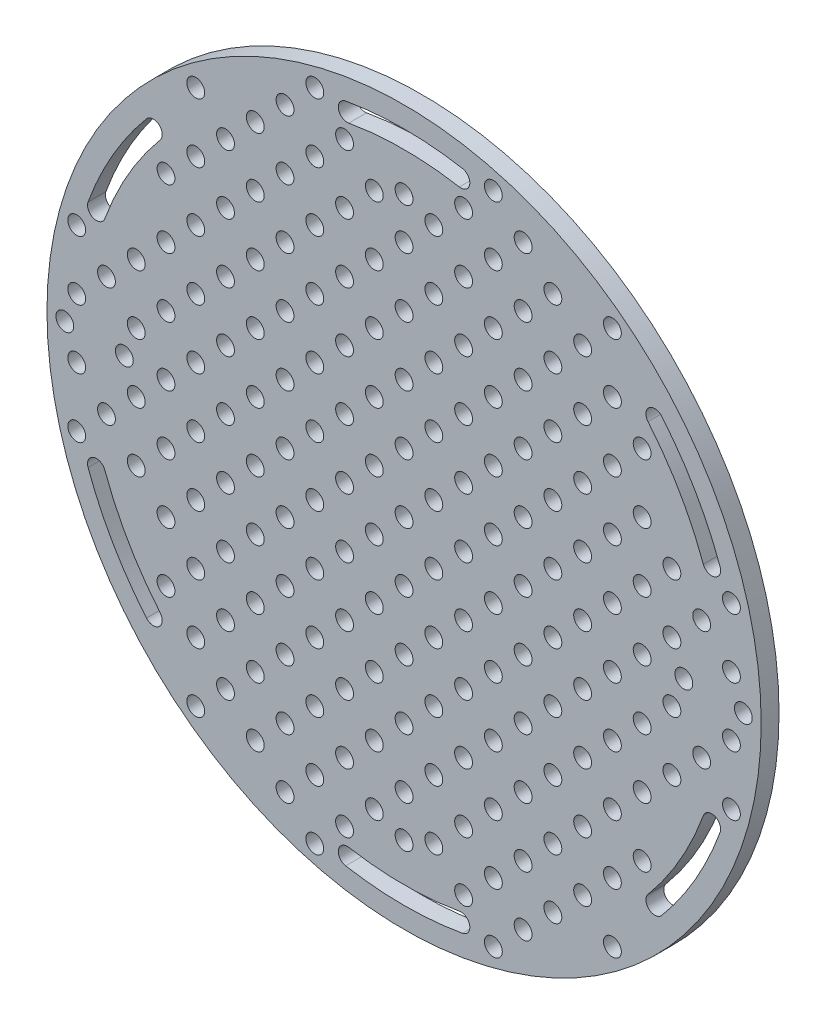
from build123d import *

# Parameters (mm, degrees)
ESQUISSE1_R             = 50
ESQUISSE1_R_2           = 1.5
BOSS_EXTRU_1_DEPTH      = 3
ESQUISSE2_R             = 60
ESQUISSE2_R_2           = 50
BOSS_EXTRU_2_DEPTH      = 3
ESQUISSE3_R             = 1.5
ENL_V_MAT_EXTRU_1_DEPTH = 3
ENL_V_MAT_EXTRU_3_DEPTH = 3
ESQUISSE10_R            = 1.5
ENL_V_MAT_EXTRU_7_DEPTH = 3
ESQUISSE11_R            = 1.5
ENL_V_MAT_EXTRU_8_DEPTH = 3


with BuildPart() as part:
    # Esquisse1 → Boss.-Extru.1 (new body)
    with BuildSketch(Plane.XY):
        Circle(ESQUISSE1_R)
        with Locations((0, 47)):
            Circle(ESQUISSE1_R_2, mode=Mode.SUBTRACT)
        with Locations((47, 0)):
            Circle(ESQUISSE1_R_2, mode=Mode.SUBTRACT)
        with Locations((0, -47)):
            Circle(ESQUISSE1_R_2, mode=Mode.SUBTRACT)
        with Locations((-47, 0)):
            Circle(ESQUISSE1_R_2, mode=Mode.SUBTRACT)
    extrude(amount=BOSS_EXTRU_1_DEPTH)

    # Esquisse2 → Boss.-Extru.2 (add)
    with BuildSketch(Plane.XY.offset(3)):
        Circle(ESQUISSE2_R)
        Circle(ESQUISSE2_R_2, mode=Mode.SUBTRACT)
    extrude(amount=-BOSS_EXTRU_2_DEPTH)

    # Esquisse3 → Enlèv. mat.-Extru.1 (cut)
    with BuildSketch(Plane.XY.offset(3)):
        Circle(ESQUISSE3_R)
        with Locations((10, 0)):
            Circle(ESQUISSE3_R)
        with Locations((20, 0)):
            Circle(ESQUISSE3_R)
        with Locations((30, 0)):
            Circle(ESQUISSE3_R)
        with Locations((40, 0)):
            Circle(ESQUISSE3_R)
        with Locations((10, 10)):
            Circle(ESQUISSE3_R)
        with Locations((20, 10)):
            Circle(ESQUISSE3_R)
        with Locations((30, 10)):
            Circle(ESQUISSE3_R)
        with Locations((40, 10)):
            Circle(ESQUISSE3_R)
        with Locations((10, 20)):
            Circle(ESQUISSE3_R)
        with Locations((20, 20)):
            Circle(ESQUISSE3_R)
        with Locations((30, 20)):
            Circle(ESQUISSE3_R)
        with Locations((40, 20)):
            Circle(ESQUISSE3_R)
        with Locations((10, 30)):
            Circle(ESQUISSE3_R)
        with Locations((20, 30)):
            Circle(ESQUISSE3_R)
        with Locations((30, 30)):
            Circle(ESQUISSE3_R)
        with Locations((10, 40)):
            Circle(ESQUISSE3_R)
        with Locations((20, 40)):
            Circle(ESQUISSE3_R)
        with Locations((0, 10)):
            Circle(ESQUISSE3_R)
        with Locations((0, 20)):
            Circle(ESQUISSE3_R)
        with Locations((0, 30)):
            Circle(ESQUISSE3_R)
        with Locations((0, 40)):
            Circle(ESQUISSE3_R)
        with Locations((-20, 40)):
            Circle(ESQUISSE3_R)
        with Locations((-10, 40)):
            Circle(ESQUISSE3_R)
        with Locations((-30, 30)):
            Circle(ESQUISSE3_R)
        with Locations((-20, 30)):
            Circle(ESQUISSE3_R)
        with Locations((-10, 30)):
            Circle(ESQUISSE3_R)
        with Locations((-40, 20)):
            Circle(ESQUISSE3_R)
        with Locations((-30, 20)):
            Circle(ESQUISSE3_R)
        with Locations((-20, 20)):
            Circle(ESQUISSE3_R)
        with Locations((-10, 20)):
            Circle(ESQUISSE3_R)
        with Locations((-40, 10)):
            Circle(ESQUISSE3_R)
        with Locations((-30, 10)):
            Circle(ESQUISSE3_R)
        with Locations((-20, 10)):
            Circle(ESQUISSE3_R)
        with Locations((-10, 10)):
            Circle(ESQUISSE3_R)
        with Locations((-40, 0)):
            Circle(ESQUISSE3_R)
        with Locations((-30, 0)):
            Circle(ESQUISSE3_R)
        with Locations((-20, 0)):
            Circle(ESQUISSE3_R)
        with Locations((-10, 0)):
            Circle(ESQUISSE3_R)
        with Locations((-10, -10)):
            Circle(ESQUISSE3_R)
        with Locations((-20, -10)):
            Circle(ESQUISSE3_R)
        with Locations((-30, -10)):
            Circle(ESQUISSE3_R)
        with Locations((-40, -10)):
            Circle(ESQUISSE3_R)
        with Locations((-10, -20)):
            Circle(ESQUISSE3_R)
        with Locations((-20, -20)):
            Circle(ESQUISSE3_R)
        with Locations((-30, -20)):
            Circle(ESQUISSE3_R)
        with Locations((-40, -20)):
            Circle(ESQUISSE3_R)
        with Locations((-10, -30)):
            Circle(ESQUISSE3_R)
        with Locations((-20, -30)):
            Circle(ESQUISSE3_R)
        with Locations((-30, -30)):
            Circle(ESQUISSE3_R)
        with Locations((-10, -40)):
            Circle(ESQUISSE3_R)
        with Locations((-20, -40)):
            Circle(ESQUISSE3_R)
        with Locations((0, -40)):
            Circle(ESQUISSE3_R)
        with Locations((0, -30)):
            Circle(ESQUISSE3_R)
        with Locations((0, -20)):
            Circle(ESQUISSE3_R)
        with Locations((0, -10)):
            Circle(ESQUISSE3_R)
        with Locations((20, -40)):
            Circle(ESQUISSE3_R)
        with Locations((10, -40)):
            Circle(ESQUISSE3_R)
        with Locations((30, -30)):
            Circle(ESQUISSE3_R)
        with Locations((20, -30)):
            Circle(ESQUISSE3_R)
        with Locations((10, -30)):
            Circle(ESQUISSE3_R)
        with Locations((40, -20)):
            Circle(ESQUISSE3_R)
        with Locations((30, -20)):
            Circle(ESQUISSE3_R)
        with Locations((20, -20)):
            Circle(ESQUISSE3_R)
        with Locations((10, -20)):
            Circle(ESQUISSE3_R)
        with Locations((40, -10)):
            Circle(ESQUISSE3_R)
        with Locations((30, -10)):
            Circle(ESQUISSE3_R)
        with Locations((20, -10)):
            Circle(ESQUISSE3_R)
        with Locations((10, -10)):
            Circle(ESQUISSE3_R)
    extrude(amount=-ENL_V_MAT_EXTRU_1_DEPTH, mode=Mode.SUBTRACT)

    # Esquisse4 → Enlèv. mat.-Extru.3 (cut)
    with BuildSketch(Plane.XY.offset(3)):
        with BuildLine():
            ThreePointArc((9.811122038, 55.641638045), (0, 56.5), (-9.811122038, 55.641638045))
            ThreePointArc((-9.811122038, 55.641638045), (-11.027861401, 53.903954149), (-9.290177505, 52.687214786))
            ThreePointArc((-9.290177505, 52.687214786), (0, 53.5), (9.290177505, 52.687214786))
            ThreePointArc((9.290177505, 52.687214786), (11.027861401, 53.903954149), (9.811122038, 55.641638045))
        make_face()
        with BuildLine():
            ThreePointArc((53.092633074, 19.324138098), (48.930435314, 28.25), (43.281511036, 36.317499947))
            ThreePointArc((43.281511036, 36.317499947), (41.168262957, 36.502385197), (40.983377707, 34.389137118))
            ThreePointArc((40.983377707, 34.389137118), (46.332359102, 26.75), (50.273555212, 18.298077668))
            ThreePointArc((50.273555212, 18.298077668), (52.196124358, 17.401568952), (53.092633074, 19.324138098))
        make_face()
        with BuildLine():
            ThreePointArc((43.281511036, -36.317499947), (48.930435314, -28.25), (53.092633074, -19.324138098))
            ThreePointArc((53.092633074, -19.324138098), (52.196124358, -17.401568952), (50.273555212, -18.298077668))
            ThreePointArc((50.273555212, -18.298077668), (46.332359102, -26.75), (40.983377707, -34.389137118))
            ThreePointArc((40.983377707, -34.389137118), (41.168262957, -36.502385197), (43.281511036, -36.317499947))
        make_face()
        with BuildLine():
            ThreePointArc((-9.811122038, -55.641638045), (0, -56.5), (9.811122038, -55.641638045))
            ThreePointArc((9.811122038, -55.641638045), (11.027861401, -53.903954149), (9.290177505, -52.687214786))
            ThreePointArc((9.290177505, -52.687214786), (0, -53.5), (-9.290177505, -52.687214786))
            ThreePointArc((-9.290177505, -52.687214786), (-11.027861401, -53.903954149), (-9.811122038, -55.641638045))
        make_face()
        with BuildLine():
            ThreePointArc((-53.092633074, -19.324138098), (-48.930435314, -28.25), (-43.281511036, -36.317499947))
            ThreePointArc((-43.281511036, -36.317499947), (-41.168262957, -36.502385197), (-40.983377707, -34.389137118))
            ThreePointArc((-40.983377707, -34.389137118), (-46.332359102, -26.75), (-50.273555212, -18.298077668))
            ThreePointArc((-50.273555212, -18.298077668), (-52.196124358, -17.401568952), (-53.092633074, -19.324138098))
        make_face()
        with BuildLine():
            ThreePointArc((-43.281511036, 36.317499947), (-48.930435314, 28.25), (-53.092633074, 19.324138098))
            ThreePointArc((-53.092633074, 19.324138098), (-52.196124358, 17.401568952), (-50.273555212, 18.298077668))
            ThreePointArc((-50.273555212, 18.298077668), (-46.332359102, 26.75), (-40.983377707, 34.389137118))
            ThreePointArc((-40.983377707, 34.389137118), (-41.168262957, 36.502385197), (-43.281511036, 36.317499947))
        make_face()
    extrude(amount=-ENL_V_MAT_EXTRU_3_DEPTH, mode=Mode.SUBTRACT)

    # Esquisse10 → Enlèv. mat.-Extru.7 (cut)
    with BuildSketch(Plane(origin=(0, 0, 0), x_dir=(-1, 0, 0), z_dir=(0, 0, -1))):
        with Locations((-10, 50)):
            Circle(ESQUISSE10_R)
        with Locations((-20, 50)):
            Circle(ESQUISSE10_R)
        with Locations((-30, 40)):
            Circle(ESQUISSE10_R)
        with Locations((-40, 30)):
            Circle(ESQUISSE10_R)
        with Locations((-50, 10)):
            Circle(ESQUISSE10_R)
        with Locations((-57, 0)):
            Circle(ESQUISSE10_R)
        with Locations((-50, -10)):
            Circle(ESQUISSE10_R)
        with Locations((-40, -30)):
            Circle(ESQUISSE10_R)
        with Locations((-30, -40)):
            Circle(ESQUISSE10_R)
        with Locations((-20, -50)):
            Circle(ESQUISSE10_R)
        with Locations((-10, -50)):
            Circle(ESQUISSE10_R)
        with Locations((10, -50)):
            Circle(ESQUISSE10_R)
        with Locations((20, -50)):
            Circle(ESQUISSE10_R)
        with Locations((30, -40)):
            Circle(ESQUISSE10_R)
        with Locations((40, -30)):
            Circle(ESQUISSE10_R)
        with Locations((50, -10)):
            Circle(ESQUISSE10_R)
        with Locations((57, 0)):
            Circle(ESQUISSE10_R)
        with Locations((50, 10)):
            Circle(ESQUISSE10_R)
        with Locations((40, 30)):
            Circle(ESQUISSE10_R)
        with Locations((30, 40)):
            Circle(ESQUISSE10_R)
        with Locations((20, 50)):
            Circle(ESQUISSE10_R)
        with Locations((10, 50)):
            Circle(ESQUISSE10_R)
    extrude(amount=-ENL_V_MAT_EXTRU_7_DEPTH, mode=Mode.SUBTRACT)

    # Esquisse11 → Enlèv. mat.-Extru.8 (cut)
    with BuildSketch(Plane(origin=(0, 0, 0), x_dir=(-1, 0, 0), z_dir=(0, 0, -1))):
        with Locations((5, 5)):
            Circle(ESQUISSE11_R)
        with Locations((15, 5)):
            Circle(ESQUISSE11_R)
        with Locations((25, 5)):
            Circle(ESQUISSE11_R)
        with Locations((35, 5)):
            Circle(ESQUISSE11_R)
        with Locations((45, 5)):
            Circle(ESQUISSE11_R)
        with Locations((55, 5)):
            Circle(ESQUISSE11_R)
        with Locations((15, 15)):
            Circle(ESQUISSE11_R)
        with Locations((25, 15)):
            Circle(ESQUISSE11_R)
        with Locations((35, 15)):
            Circle(ESQUISSE11_R)
        with Locations((45, 15)):
            Circle(ESQUISSE11_R)
        with Locations((55, 15)):
            Circle(ESQUISSE11_R)
        with Locations((15, 25)):
            Circle(ESQUISSE11_R)
        with Locations((25, 25)):
            Circle(ESQUISSE11_R)
        with Locations((35, 25)):
            Circle(ESQUISSE11_R)
        with Locations((15, 35)):
            Circle(ESQUISSE11_R)
        with Locations((25, 35)):
            Circle(ESQUISSE11_R)
        with Locations((35, 35)):
            Circle(ESQUISSE11_R)
        with Locations((15, 45)):
            Circle(ESQUISSE11_R)
        with Locations((25, 45)):
            Circle(ESQUISSE11_R)
        with Locations((35, 45)):
            Circle(ESQUISSE11_R)
        with Locations((15, 55)):
            Circle(ESQUISSE11_R)
        with Locations((5, 15)):
            Circle(ESQUISSE11_R)
        with Locations((5, 25)):
            Circle(ESQUISSE11_R)
        with Locations((5, 35)):
            Circle(ESQUISSE11_R)
        with Locations((5, 45)):
            Circle(ESQUISSE11_R)
        with Locations((-5, 45)):
            Circle(ESQUISSE11_R)
        with Locations((-5, 35)):
            Circle(ESQUISSE11_R)
        with Locations((-5, 25)):
            Circle(ESQUISSE11_R)
        with Locations((-5, 15)):
            Circle(ESQUISSE11_R)
        with Locations((-15, 55)):
            Circle(ESQUISSE11_R)
        with Locations((-35, 45)):
            Circle(ESQUISSE11_R)
        with Locations((-25, 45)):
            Circle(ESQUISSE11_R)
        with Locations((-15, 45)):
            Circle(ESQUISSE11_R)
        with Locations((-35, 35)):
            Circle(ESQUISSE11_R)
        with Locations((-25, 35)):
            Circle(ESQUISSE11_R)
        with Locations((-15, 35)):
            Circle(ESQUISSE11_R)
        with Locations((-35, 25)):
            Circle(ESQUISSE11_R)
        with Locations((-25, 25)):
            Circle(ESQUISSE11_R)
        with Locations((-15, 25)):
            Circle(ESQUISSE11_R)
        with Locations((-55, 15)):
            Circle(ESQUISSE11_R)
        with Locations((-45, 15)):
            Circle(ESQUISSE11_R)
        with Locations((-35, 15)):
            Circle(ESQUISSE11_R)
        with Locations((-25, 15)):
            Circle(ESQUISSE11_R)
        with Locations((-15, 15)):
            Circle(ESQUISSE11_R)
        with Locations((-55, 5)):
            Circle(ESQUISSE11_R)
        with Locations((-45, 5)):
            Circle(ESQUISSE11_R)
        with Locations((-35, 5)):
            Circle(ESQUISSE11_R)
        with Locations((-25, 5)):
            Circle(ESQUISSE11_R)
        with Locations((-15, 5)):
            Circle(ESQUISSE11_R)
        with Locations((-5, 5)):
            Circle(ESQUISSE11_R)
        with Locations((-5, -5)):
            Circle(ESQUISSE11_R)
        with Locations((-15, -5)):
            Circle(ESQUISSE11_R)
        with Locations((-25, -5)):
            Circle(ESQUISSE11_R)
        with Locations((-35, -5)):
            Circle(ESQUISSE11_R)
        with Locations((-45, -5)):
            Circle(ESQUISSE11_R)
        with Locations((-55, -5)):
            Circle(ESQUISSE11_R)
        with Locations((-15, -15)):
            Circle(ESQUISSE11_R)
        with Locations((-25, -15)):
            Circle(ESQUISSE11_R)
        with Locations((-35, -15)):
            Circle(ESQUISSE11_R)
        with Locations((-45, -15)):
            Circle(ESQUISSE11_R)
        with Locations((-55, -15)):
            Circle(ESQUISSE11_R)
        with Locations((-15, -25)):
            Circle(ESQUISSE11_R)
        with Locations((-25, -25)):
            Circle(ESQUISSE11_R)
        with Locations((-35, -25)):
            Circle(ESQUISSE11_R)
        with Locations((-15, -35)):
            Circle(ESQUISSE11_R)
        with Locations((-25, -35)):
            Circle(ESQUISSE11_R)
        with Locations((-35, -35)):
            Circle(ESQUISSE11_R)
        with Locations((-15, -45)):
            Circle(ESQUISSE11_R)
        with Locations((-25, -45)):
            Circle(ESQUISSE11_R)
        with Locations((-35, -45)):
            Circle(ESQUISSE11_R)
        with Locations((-15, -55)):
            Circle(ESQUISSE11_R)
        with Locations((-5, -15)):
            Circle(ESQUISSE11_R)
        with Locations((-5, -25)):
            Circle(ESQUISSE11_R)
        with Locations((-5, -35)):
            Circle(ESQUISSE11_R)
        with Locations((-5, -45)):
            Circle(ESQUISSE11_R)
        with Locations((5, -45)):
            Circle(ESQUISSE11_R)
        with Locations((5, -35)):
            Circle(ESQUISSE11_R)
        with Locations((5, -25)):
            Circle(ESQUISSE11_R)
        with Locations((5, -15)):
            Circle(ESQUISSE11_R)
        with Locations((15, -55)):
            Circle(ESQUISSE11_R)
        with Locations((35, -45)):
            Circle(ESQUISSE11_R)
        with Locations((25, -45)):
            Circle(ESQUISSE11_R)
        with Locations((15, -45)):
            Circle(ESQUISSE11_R)
        with Locations((35, -35)):
            Circle(ESQUISSE11_R)
        with Locations((25, -35)):
            Circle(ESQUISSE11_R)
        with Locations((15, -35)):
            Circle(ESQUISSE11_R)
        with Locations((35, -25)):
            Circle(ESQUISSE11_R)
        with Locations((25, -25)):
            Circle(ESQUISSE11_R)
        with Locations((15, -25)):
            Circle(ESQUISSE11_R)
        with Locations((55, -15)):
            Circle(ESQUISSE11_R)
        with Locations((45, -15)):
            Circle(ESQUISSE11_R)
        with Locations((35, -15)):
            Circle(ESQUISSE11_R)
        with Locations((25, -15)):
            Circle(ESQUISSE11_R)
        with Locations((15, -15)):
            Circle(ESQUISSE11_R)
        with Locations((55, -5)):
            Circle(ESQUISSE11_R)
        with Locations((45, -5)):
            Circle(ESQUISSE11_R)
        with Locations((35, -5)):
            Circle(ESQUISSE11_R)
        with Locations((25, -5)):
            Circle(ESQUISSE11_R)
        with Locations((15, -5)):
            Circle(ESQUISSE11_R)
        with Locations((5, -5)):
            Circle(ESQUISSE11_R)
    extrude(amount=-ENL_V_MAT_EXTRU_8_DEPTH, mode=Mode.SUBTRACT)


solid = part.part
